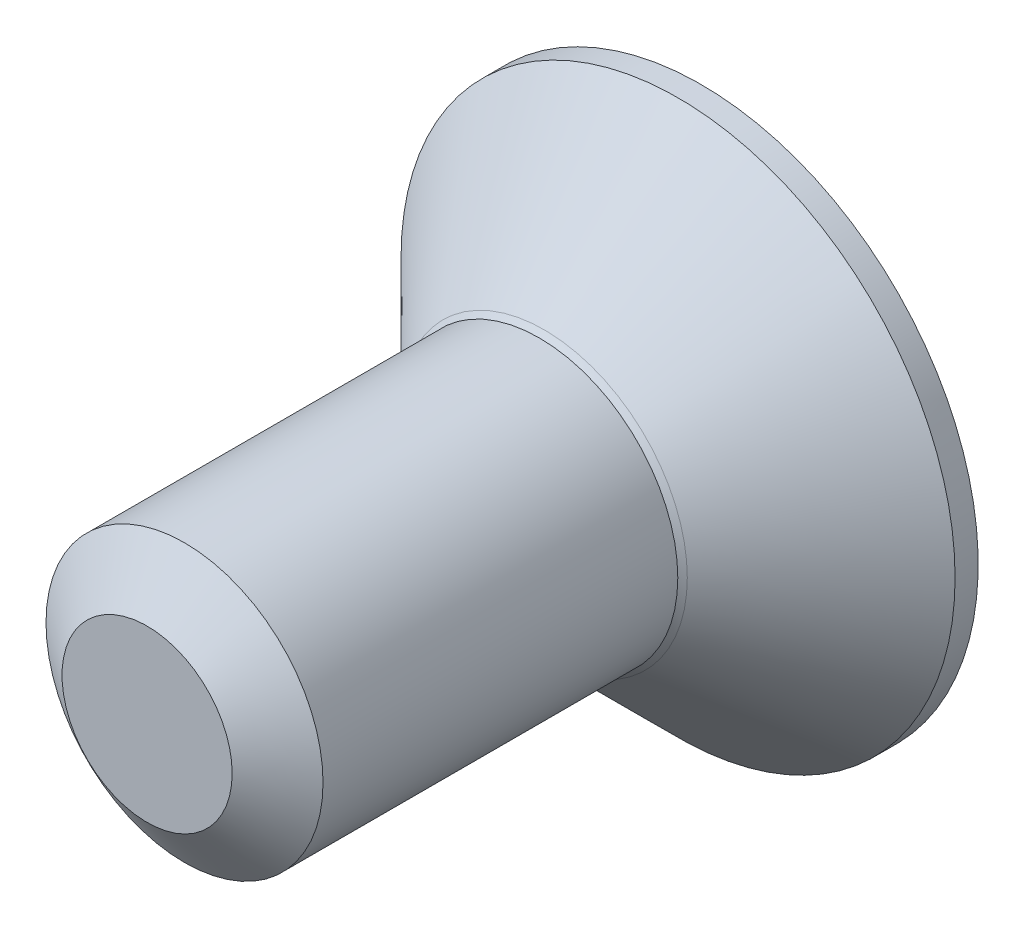
from build123d import *

# Parameters (mm, degrees)
SKETCH1_R          = 1.5
EXTRUDE1_DEPTH     = 6
SKETCH6_R          = 3
EXTRUDE2_DEPTH     = 1.7
CUT_EXTRUDE1_DEPTH = 1.5
SKETCH8_R          = 1.154700538
CUT_EXTRUDE2_DEPTH = 7
CUT_EXTRUDE2_TAPER = 45


with BuildPart() as part:
    # Sketch1 → Extrude1 (new body)
    with BuildSketch(Plane.XY):
        Circle(SKETCH1_R)
    extrude(amount=-EXTRUDE1_DEPTH)

    # Sketch4 → Cut-Revolve1 (revolve, cut)
    with BuildSketch(Plane(origin=(0, 0, 0), x_dir=(0, 0, -1), z_dir=(1, 0, 0)), mode=Mode.PRIVATE) as cut_revolve1_sk:
        Polygon((0.405251783, 1.5), (0, 0.921240474), (0, 1.5), align=None)
    revolve(cut_revolve1_sk.sketch.rotate(Axis((0, 0, 0), (0, 0, -1)), 90), axis=Axis((0, 0, 0), (0, 0, -1)), mode=Mode.SUBTRACT)  # turned: the seam where the file's is

    # Sketch6 → Extrude2 (add)
    with BuildSketch(Plane(origin=(0, 0, -6), x_dir=(-1, 0, 0), z_dir=(0, 0, -1))):
        Circle(SKETCH6_R)
    extrude(amount=-EXTRUDE2_DEPTH)

    # Sketch10 → Cut-Revolve2 (revolve, cut)
    with BuildSketch(Plane(origin=(0, 0, 0), x_dir=(0, 0, -1), z_dir=(1, 0, 0)), mode=Mode.PRIVATE) as cut_revolve2_sk:
        Polygon((5.75, -3), (4.3, -1.55), (4.3, -3), align=None)
    revolve(cut_revolve2_sk.sketch.rotate(Axis((0, 0, 0), (0, 0, -1)), 270), axis=Axis((0, 0, 0), (0, 0, -1)), mode=Mode.SUBTRACT)  # turned: the seam where the file's is

    # Sketch11 → Revolve1 (revolve)
    with BuildSketch(Plane(origin=(0, 0, 0), x_dir=(0, 0, -1), z_dir=(1, 0, 0)), mode=Mode.PRIVATE) as revolve1_sk:
        with BuildLine():
            Line((3.395250469, 1.175240474), (3.395250469, 0))
            Line((3.395250469, 0), (4.3, 0))
            Line((4.3, 0), (4.3, 1.55))
            ThreePointArc((4.3, 1.55), (3.884897387, 1.272637301), (3.395250469, 1.175240474))
        make_face()
    revolve(revolve1_sk.sketch.rotate(Axis((0, 0, 0), (0, 0, -1)), 90), axis=Axis((0, 0, 0), (0, 0, -1)))  # turned: the seam where the file's is

    # Sketch7 → Cut-Extrude1 (cut)
    with BuildSketch(Plane.XY.offset(-6)):
        Polygon((0, 1.154700538), (-1, 0.577350269), (-1, -0.577350269), (0, -1.154700538), (1, -0.577350269), (1, 0.577350269), align=None)
    extrude(amount=CUT_EXTRUDE1_DEPTH, mode=Mode.SUBTRACT)

    # Sketch8 → Cut-Extrude2 (cut, through all)
    with BuildSketch(Plane.XY.offset(-6)):
        Circle(SKETCH8_R)
    extrude(amount=CUT_EXTRUDE2_DEPTH, taper=CUT_EXTRUDE2_TAPER, mode=Mode.SUBTRACT)


solid = part.part
